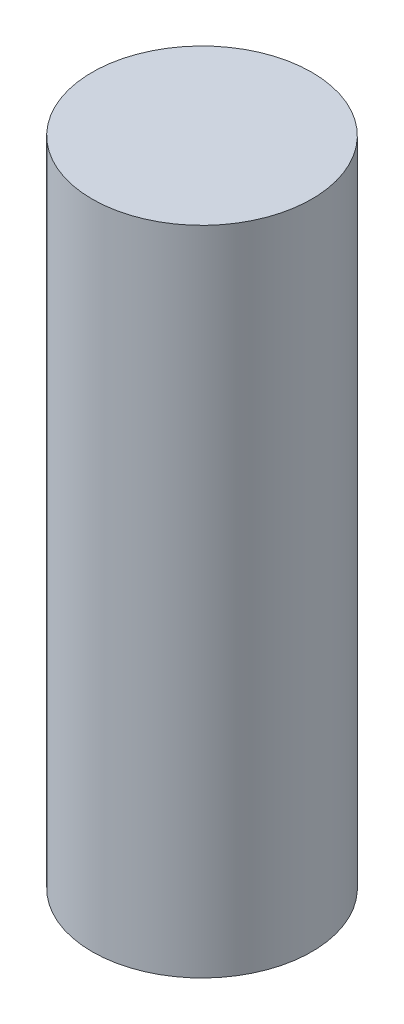
from build123d import *

# Parameters (mm, degrees)
SKETCH1_R           = 3
BOSS_EXTRUDE1_DEPTH = 17.8


with BuildPart() as part:
    # Sketch1 → Boss-Extrude1 (new body)
    with BuildSketch(Plane(origin=(0, 0, 0), x_dir=(1, 0, 0), z_dir=(0, 1, 0))):
        Circle(SKETCH1_R)
    extrude(amount=BOSS_EXTRUDE1_DEPTH)


solid = part.part
